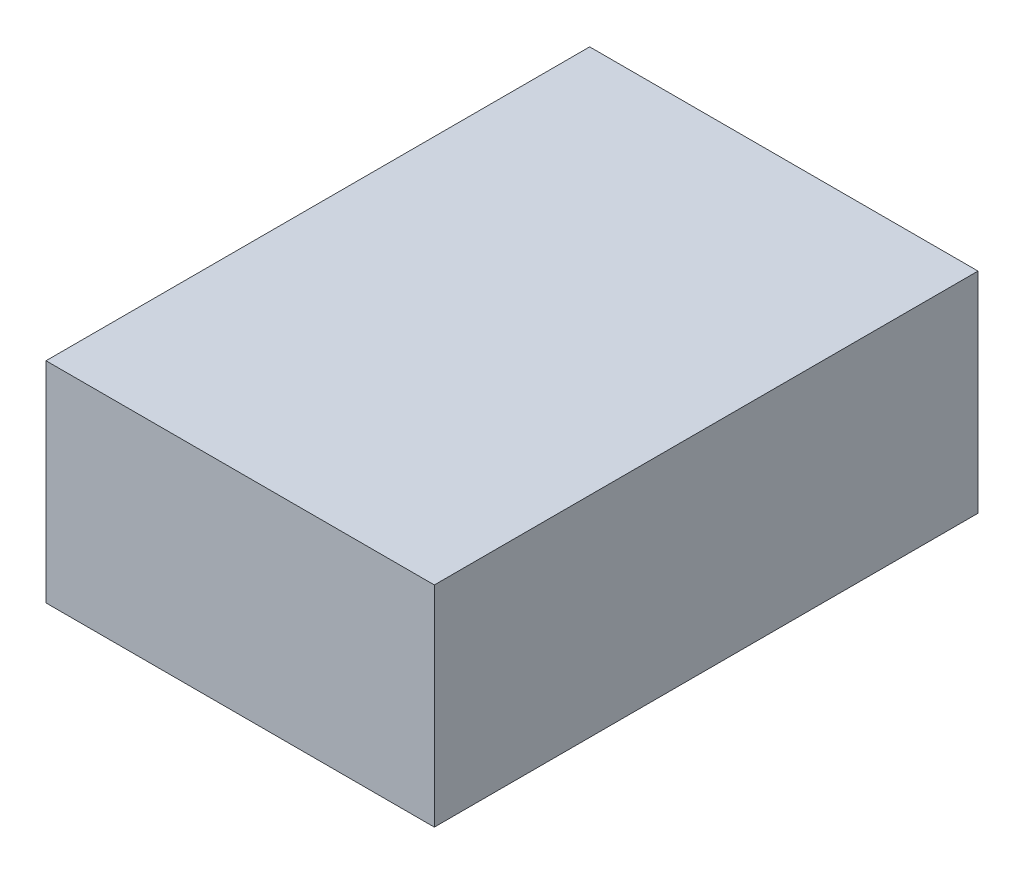
from build123d import *

# Parameters (mm, degrees)
SKETCH1_W           = 12.7
SKETCH1_H           = 6.86
BOSS_EXTRUDE1_DEPTH = 17.78


with BuildPart() as part:
    # Sketch1 → Boss-Extrude1 (new body)
    with BuildSketch(Plane.XY):
        Rectangle(SKETCH1_W, SKETCH1_H)
    extrude(amount=BOSS_EXTRUDE1_DEPTH)


solid = part.part
